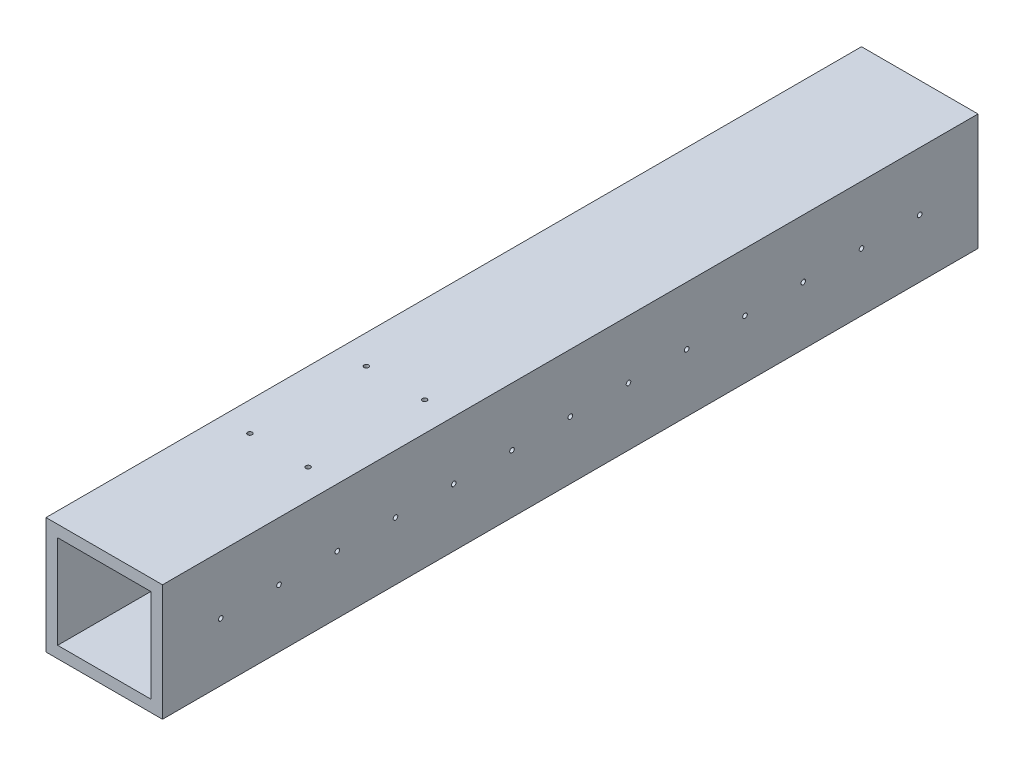
from build123d import *

# Parameters (mm, degrees)
SKETCH1_W               = 25.4
SKETCH1_H               = 25.4
SKETCH1_W_2             = 20.32
SKETCH1_H_2             = 20.32
BOSS_EXTRUDE1_DEPTH     = 177.8
SKETCH2_R               = 0.5
CUT_EXTRUDE1_DEPTH      = 1
CUT_EXTRUDE1_DEPTH_BACK = 26.4
SKETCH4_R               = 0.5
CUT_EXTRUDE3_DEPTH      = 26.4


with BuildPart() as part:
    # Sketch1 → Boss-Extrude1 (new body)
    with BuildSketch(Plane.XY):
        with Locations((12.216190476, 0.846666667)):
            Rectangle(SKETCH1_W, SKETCH1_H)
        with Locations((12.216190476, 0.846666667)):
            Rectangle(SKETCH1_W_2, SKETCH1_H_2, mode=Mode.SUBTRACT)
    extrude(amount=BOSS_EXTRUDE1_DEPTH)

    # Sketch2 → Cut-Extrude1 (cut, two sides)
    with BuildSketch(Plane(origin=(24.916190476, 0, 0), x_dir=(0, 0, -1), z_dir=(1, 0, 0))) as cut_extrude1_sk:
        with Locations((-165.1, 0.846666667)):
            Circle(SKETCH2_R)
        with Locations((-152.4, 0.846666667)):
            Circle(SKETCH2_R)
        with Locations((-139.7, 0.846666667)):
            Circle(SKETCH2_R)
        with Locations((-127, 0.846666667)):
            Circle(SKETCH2_R)
        with Locations((-114.3, 0.846666667)):
            Circle(SKETCH2_R)
        with Locations((-101.6, 0.846666667)):
            Circle(SKETCH2_R)
        with Locations((-88.9, 0.846666667)):
            Circle(SKETCH2_R)
        with Locations((-76.2, 0.846666667)):
            Circle(SKETCH2_R)
        with Locations((-63.5, 0.846666667)):
            Circle(SKETCH2_R)
        with Locations((-50.8, 0.846666667)):
            Circle(SKETCH2_R)
        with Locations((-38.1, 0.846666667)):
            Circle(SKETCH2_R)
        with Locations((-25.4, 0.846666667)):
            Circle(SKETCH2_R)
        with Locations((-12.7, 0.846666667)):
            Circle(SKETCH2_R)
    extrude(amount=CUT_EXTRUDE1_DEPTH, mode=Mode.SUBTRACT)
    extrude(cut_extrude1_sk.sketch, amount=-CUT_EXTRUDE1_DEPTH_BACK, mode=Mode.SUBTRACT)

    # Sketch4 → Cut-Extrude3 (cut, through all)
    with BuildSketch(Plane(origin=(0, -11.853333333, 0), x_dir=(-1, 0, 0), z_dir=(0, -1, 0))):
        with Locations((-5.866190476, -139.7)):
            Circle(SKETCH4_R)
        with Locations((-18.566190476, -139.7)):
            Circle(SKETCH4_R)
        with Locations((-5.866190476, -114.3)):
            Circle(SKETCH4_R)
        with Locations((-18.566190476, -114.3)):
            Circle(SKETCH4_R)
    extrude(amount=-CUT_EXTRUDE3_DEPTH, mode=Mode.SUBTRACT)


solid = part.part
